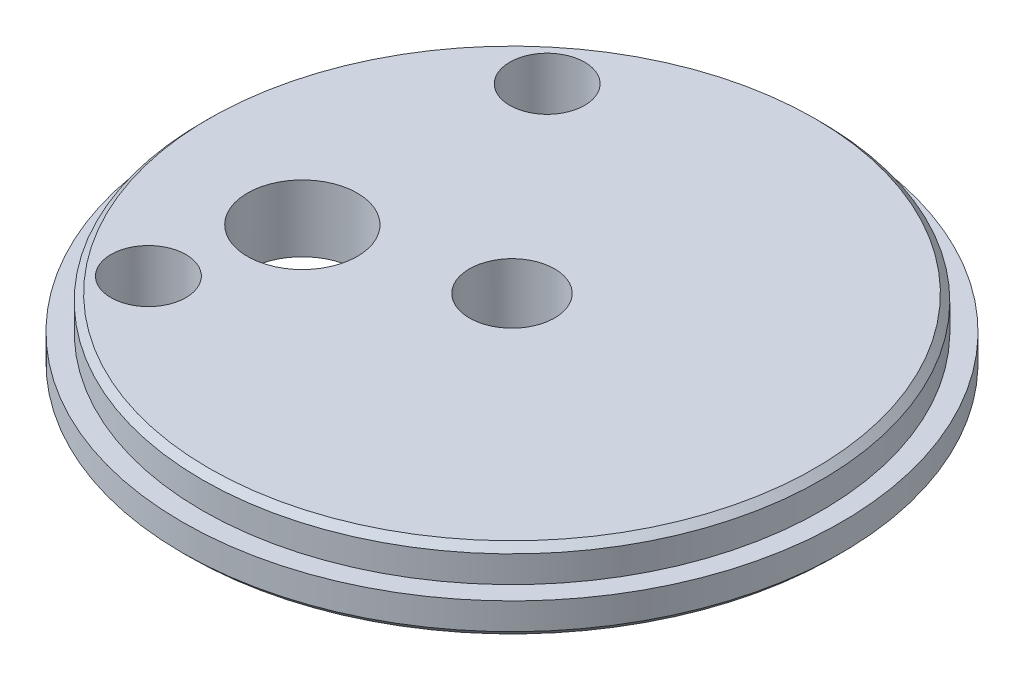
from build123d import *

# Parameters (mm, degrees)
SKETCH1_R               = 25.146
BOSS_EXTRUDE1_DEPTH     = 2.54
SKETCH2_R               = 23.622
BOSS_EXTRUDE2_DEPTH     = 2.54
SKETCH3_R               = 3.2512
SKETCH3_R_2             = 4.191
CUT_EXTRUDE1_DEPTH      = 1
CUT_EXTRUDE1_DEPTH_BACK = 6.08
SKETCH4_R               = 2.8575
CUT_EXTRUDE2_DEPTH      = 5.08
CHAMFER1_SIZE           = 0.508


with BuildPart() as part:
    # Sketch1 → Boss-Extrude1 (new body)
    with BuildSketch(Plane(origin=(0, 0, 0), x_dir=(1, 0, 0), z_dir=(0, 1, 0))):
        Circle(SKETCH1_R)
    extrude(amount=BOSS_EXTRUDE1_DEPTH)

    # Sketch2 → Boss-Extrude2 (add)
    with BuildSketch(Plane(origin=(0, 2.54, 0), x_dir=(1, 0, 0), z_dir=(0, 1, 0))):
        Circle(SKETCH2_R)
    extrude(amount=BOSS_EXTRUDE2_DEPTH)

    # Sketch3 → Cut-Extrude1 (cut, two sides)
    with BuildSketch(Plane.XZ) as cut_extrude1_sk:
        Circle(SKETCH3_R)
        with Locations((-12.537653487, 3.45997074)):
            Circle(SKETCH3_R_2)
    extrude(amount=CUT_EXTRUDE1_DEPTH, mode=Mode.SUBTRACT)
    extrude(cut_extrude1_sk.sketch, amount=-CUT_EXTRUDE1_DEPTH_BACK, mode=Mode.SUBTRACT)

    # Sketch4 → Cut-Extrude2 (cut)
    with BuildSketch(Plane.XZ):
        with Locations((-12.512560688, -15.196547307)):
            Circle(SKETCH4_R)
        with Locations((-15.019030103, 12.725091739)):
            Circle(SKETCH4_R)
    extrude(amount=-CUT_EXTRUDE2_DEPTH, mode=Mode.SUBTRACT)

    # Chamfer1
    chamfer1_edges = [part.edges().sort_by_distance(p)[0] for p in [
        (-25.146, 0, 0),
        (-23.622, 5.08, 0),
    ]]
    chamfer(chamfer1_edges, length=CHAMFER1_SIZE)


solid = part.part
